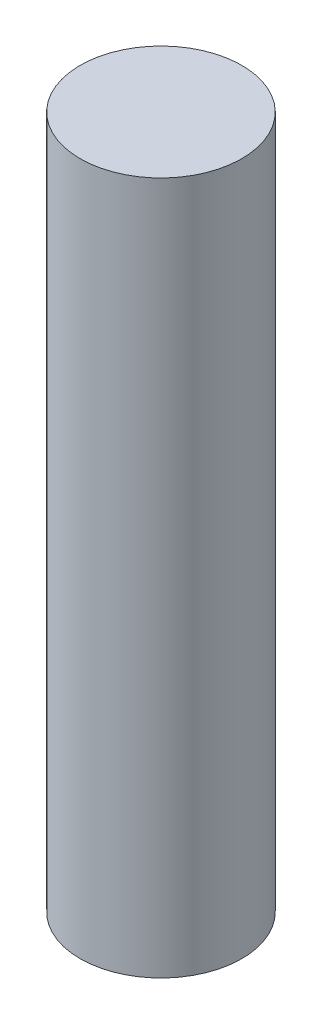
from build123d import *

# Parameters (mm, degrees)
SKETCH1_R           = 3.5
BOSS_EXTRUDE1_DEPTH = 30


with BuildPart() as part:
    # Sketch1 → Boss-Extrude1 (new body)
    with BuildSketch(Plane(origin=(0, 0, 0), x_dir=(1, 0, 0), z_dir=(0, 1, 0))):
        Circle(SKETCH1_R)
    extrude(amount=BOSS_EXTRUDE1_DEPTH)


solid = part.part
